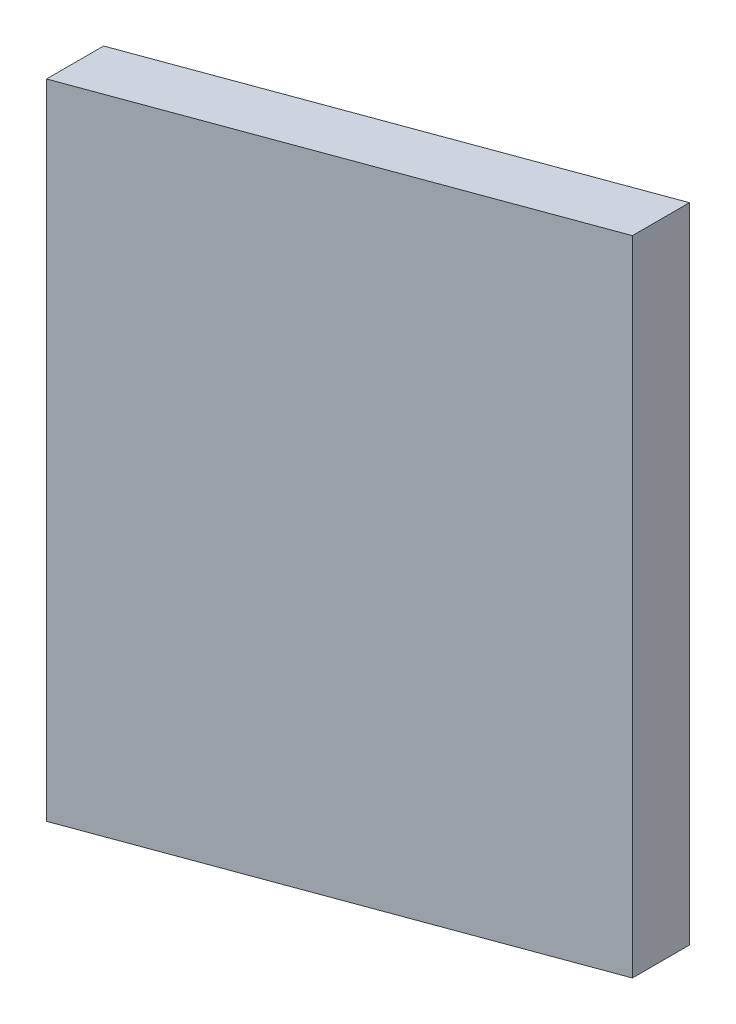
from build123d import *

# Parameters (mm, degrees)
BOSS_EXTRUDE1_DEPTH = 76.2


with BuildPart() as part:
    # Sketch1 → Boss-Extrude1 (new body)
    with BuildSketch(Plane(origin=(0, 0, 0), x_dir=(1, 0, 0), z_dir=(0, 1, 0))):
        Polygon((0, 0), (50.8, 18.636186089), (50.8, 25.4), (0, 6.763813911), align=None)
    extrude(amount=BOSS_EXTRUDE1_DEPTH)


solid = part.part
